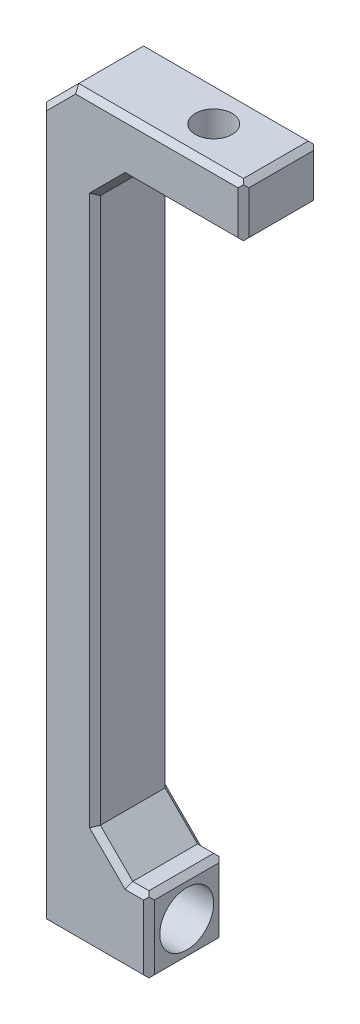
from build123d import *

# Parameters (mm, degrees)
SALIENTE_EXTRUIR1_DEPTH      = 3.5
CROQUIS2_R                   = 2.5
CORTAR_EXTRUIR1_DEPTH        = 7.25
CORTAR_EXTRUIR1_DEPTH_BACK   = 13.5
TALADRO_DE_MARGEN_PARA_M31_D = 3.4
CHAFL_N1_SIZE                = 3
CHAFL_N2_SIZE                = 0.5
CHAFL_N3_SIZE                = 0.5


with BuildPart() as part:
    # Croquis1 → Saliente-Extruir1 (new body, symmetric)
    with BuildSketch(Plane.XY):
        Polygon((6.25, 60), (6.25, 65), (0, 65), (-12.5, 65), (-12.5, 3.5), (-12.5, -3.5), (-2.5, -3.5), (-2.5, 3.5), (-7.5, 3.5), (-7.5, 60), (0, 60), align=None)
    extrude(amount=SALIENTE_EXTRUIR1_DEPTH, both=True)

    # Croquis2 → Cortar-Extruir1 (cut, two sides)
    with BuildSketch(Plane(origin=(0, 0, 0), x_dir=(0, 0, -1), z_dir=(1, 0, 0))) as cortar_extruir1_sk:
        Circle(CROQUIS2_R)
    extrude(amount=CORTAR_EXTRUIR1_DEPTH, mode=Mode.SUBTRACT)
    extrude(cortar_extruir1_sk.sketch, amount=-CORTAR_EXTRUIR1_DEPTH_BACK, mode=Mode.SUBTRACT)

    # Taladro de margen para M31 (through all)
    with Locations(Plane(origin=(0, 65, 0), x_dir=(1, 0, 0), z_dir=(0, 1, 0))):
        with Locations((0, 0)):
            Hole(TALADRO_DE_MARGEN_PARA_M31_D / 2)

    # Chaflán1
    chafl_n1_edges = [part.edges().sort_by_distance(p)[0] for p in [
        (-7.5, 60, 0),
        (-7.5, 3.5, 0),
        (-12.5, 65, 0),
    ]]
    chamfer(chafl_n1_edges, length=CHAFL_N1_SIZE)

    # Chaflán2
    chafl_n2_edges = [part.edges().sort_by_distance(p)[0] for p in [
        (-3.5, 3.5, -3.5),
        (-2.5, 0, -3.5),
        (-7.5, -3.5, -3.5),
        (6.25, 62.5, 3.5),
        (-12.5, 29.25, -3.5),
        (6.25, 62.5, -3.5),
        (-12.5, 29.25, 3.5),
        (-7.5, -3.5, 3.5),
        (-2.5, 0, 3.5),
        (-3.5, 3.5, 3.5),
        (-7.5, 31.75, -3.5),
        (-7.5, 31.75, 3.5),
        (0.875, 60, -3.5),
        (-1.625, 65, -3.5),
        (-11, 63.5, -3.5),
        (-1.625, 65, 3.5),
        (0.875, 60, 3.5),
        (-11, 63.5, 3.5),
        (-6, 5, -3.5),
        (-6, 5, 3.5),
        (-6, 58.5, -3.5),
        (-6, 58.5, 3.5),
    ]]
    chamfer(chafl_n2_edges, length=CHAFL_N2_SIZE)

    # Chaflán3
    chafl_n3_edges = [part.edges().sort_by_distance(p)[0] for p in [
        (-2.5, -3.5, 0),
        (-12.5, -3.5, 0),
        (-2.5, 3.5, 0),
        (6.25, 60, 0),
        (6.25, 65, 0),
    ]]
    chamfer(chafl_n3_edges, length=CHAFL_N3_SIZE)


solid = part.part
